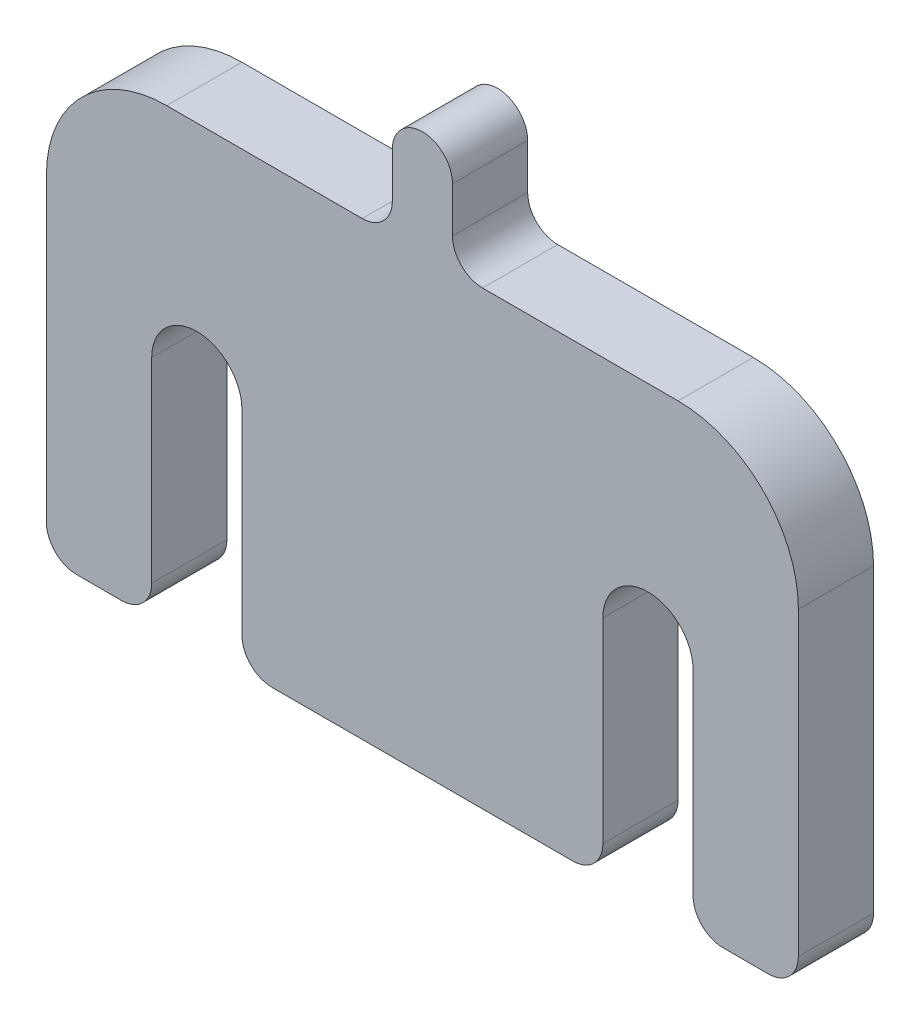
from build123d import *

# Parameters (mm, degrees)
SZKIC1_R                    = 2
DODANIE_WYCI_GNI_CIE1_DEPTH = 5
ZAOKR_GLENIE1_R             = 2
ZAOKR_GLENIE2_R             = 8


with BuildPart() as part:
    # Szkic1 → Dodanie-wyciągnięcie1 (new body)
    with BuildSketch(Plane.XY):
        with BuildLine():
            ThreePointArc((12, 0), (15, 3), (18, 0))
            Line((18, 0), (18, -15))
            Line((18, -15), (25, -15))
            Line((25, -15), (25, 15))
            Line((25, 15), (2, 15))
            Line((2, 15), (-2, 15))
            Line((-2, 15), (-25, 15))
            Line((-25, 15), (-25, -15))
            Line((-25, -15), (-18, -15))
            Line((-18, -15), (-18, 0))
            ThreePointArc((-18, 0), (-15, 3), (-12, 0))
            Line((-12, 0), (-12, -15))
            Line((-12, -15), (12, -15))
            Line((12, -15), (12, 0))
        make_face()
        with BuildLine():
            Line((-2, 15), (2, 15))
            Line((2, 15), (2, 20))
            ThreePointArc((2, 20), (0, 18), (-2, 20))
            Line((-2, 20), (-2, 15))
        make_face()
        with Locations((0, 20)):
            Circle(SZKIC1_R)
    extrude(amount=DODANIE_WYCI_GNI_CIE1_DEPTH)

    # Zaokrąglenie1
    zaokr_glenie1_edges = [part.edges().sort_by_distance(p)[0] for p in [
        (12, -15, 2.5),
        (-12, -15, 2.5),
        (-18, -15, 2.5),
        (-25, -15, 2.5),
        (-2, 15, 2.5),
        (2, 15, 2.5),
        (25, -15, 2.5),
        (18, -15, 2.5),
    ]]
    fillet(zaokr_glenie1_edges, radius=ZAOKR_GLENIE1_R)

    # Zaokrąglenie2
    zaokr_glenie2_edges = [part.edges().sort_by_distance(p)[0] for p in [
        (-25, 15, 2.5),
        (25, 15, 2.5),
    ]]
    fillet(zaokr_glenie2_edges, radius=ZAOKR_GLENIE2_R)


solid = part.part
